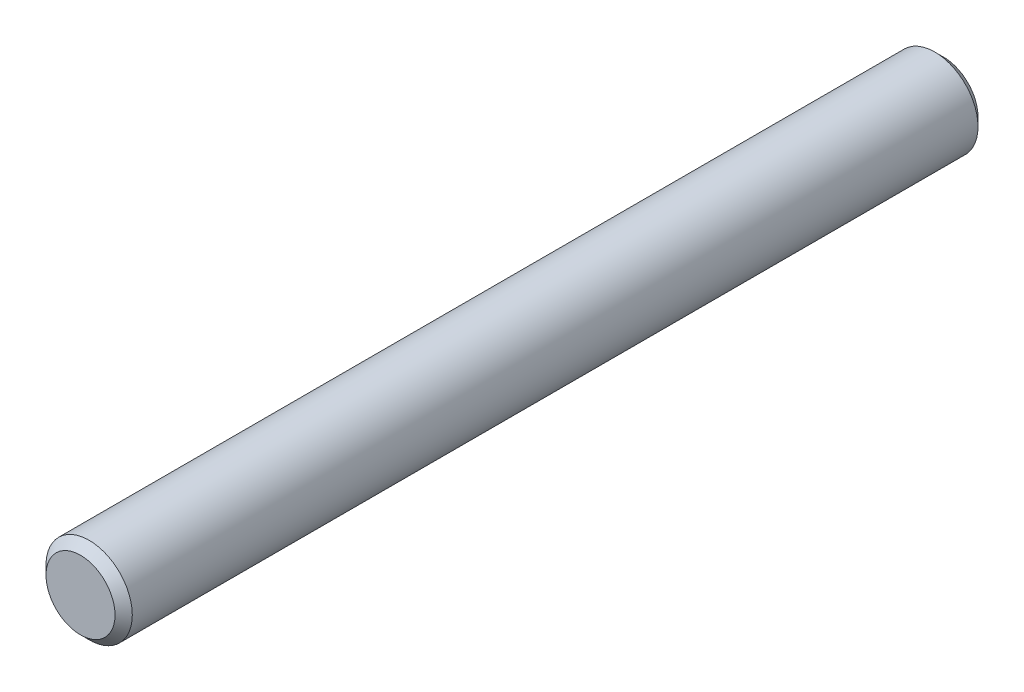
from build123d import *

# Parameters (mm, degrees)
SKETCH1_R           = 5
BOSS_EXTRUDE1_DEPTH = 100
CHAMFER1_SIZE       = 1


with BuildPart() as part:
    # Sketch1 → Boss-Extrude1 (new body)
    with BuildSketch(Plane.XY):
        Circle(SKETCH1_R)
    extrude(amount=BOSS_EXTRUDE1_DEPTH)

    # Chamfer1
    chamfer1_edges = [part.edges().sort_by_distance(p)[0] for p in [
        (-5, 0, 0),
        (-5, 0, 100),
    ]]
    chamfer(chamfer1_edges, length=CHAMFER1_SIZE)


solid = part.part
